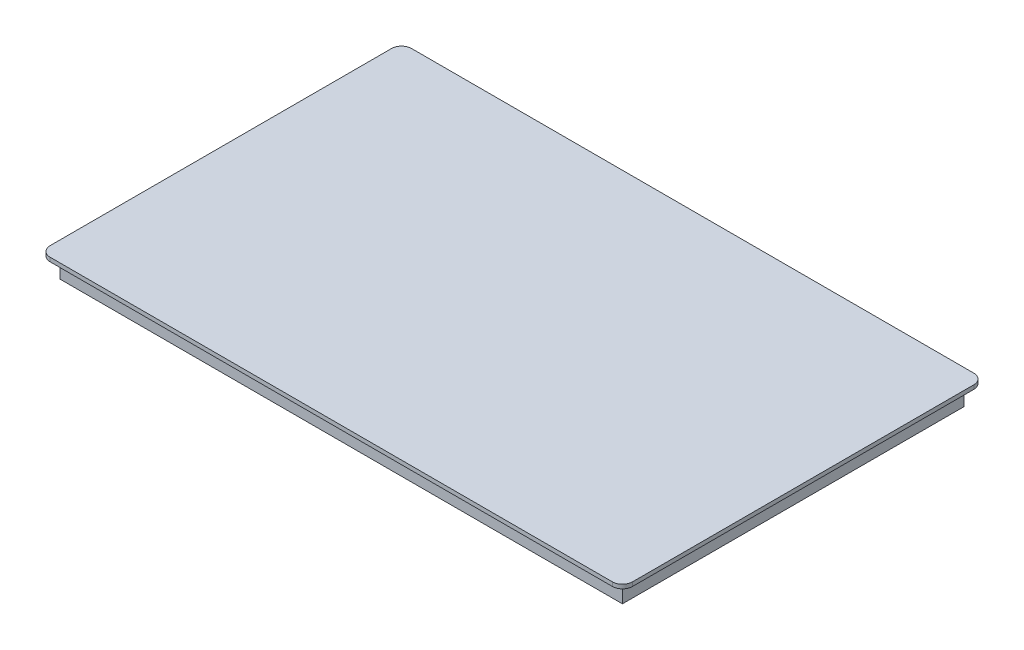
from build123d import *

# Parameters (mm, degrees)
SKETCH1_W           = 145
SKETCH1_H           = 90
BOSS_EXTRUDE1_DEPTH = 1
SKETCH2_W           = 140
SKETCH2_H           = 85
SKETCH2_W_2         = 135
SKETCH2_H_2         = 80
BOSS_EXTRUDE2_DEPTH = 5
FILLET1_R           = 2.5


with BuildPart() as part:
    # Sketch1 → Boss-Extrude1 (new body)
    with BuildSketch(Plane(origin=(0, 0, 0), x_dir=(1, 0, 0), z_dir=(0, 1, 0))):
        Rectangle(SKETCH1_W, SKETCH1_H)
    extrude(amount=-BOSS_EXTRUDE1_DEPTH)

    # Sketch2 → Boss-Extrude2 (add)
    with BuildSketch(Plane.XZ.offset(1)):
        Rectangle(SKETCH2_W, SKETCH2_H)
        Rectangle(SKETCH2_W_2, SKETCH2_H_2, mode=Mode.SUBTRACT)
    extrude(amount=BOSS_EXTRUDE2_DEPTH)

    # Fillet1
    fillet1_edges = [part.edges().sort_by_distance(p)[0] for p in [
        (72.5, -0.5, 45),
        (-72.5, -0.5, 45),
        (-72.5, -0.5, -45),
        (72.5, -0.5, -45),
    ]]
    fillet(fillet1_edges, radius=FILLET1_R)


solid = part.part
